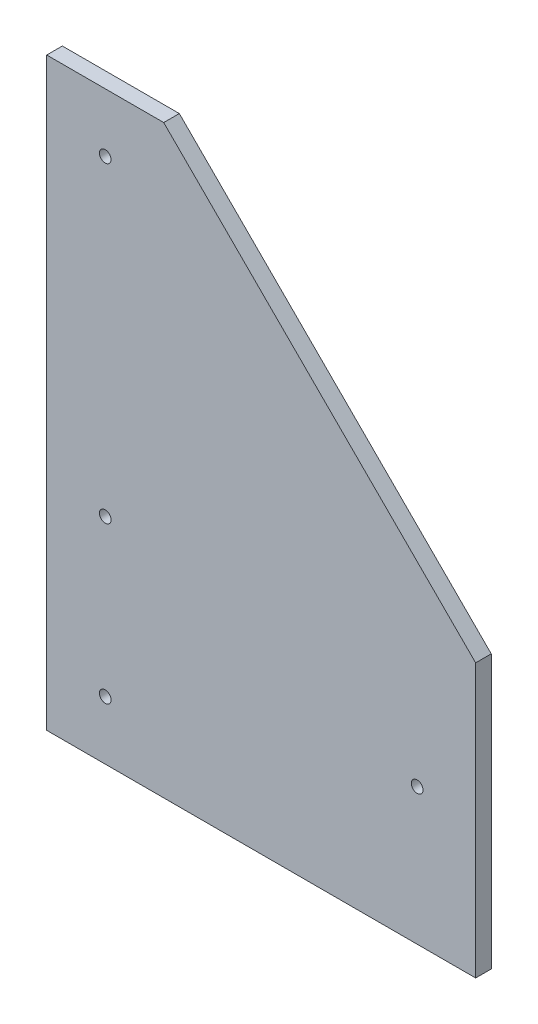
from build123d import *

# Parameters (mm, degrees)
BOSS_EXTRUDE1_DEPTH   = 5.08
F_6_CLEARANCE_HOLE1_D = 3.7973


with BuildPart() as part:
    # Sketch1 → Boss-Extrude1 (new body)
    with BuildSketch(Plane.XY):
        Polygon((0, 0), (139.7, 0), (139.7, 88.9), (38.1, 190.5), (0, 190.5), align=None)
    extrude(amount=BOSS_EXTRUDE1_DEPTH)

    # #6 Clearance Hole1 (through all)
    with Locations(Plane.XY.offset(5.08)):
        with Locations((120.65, 44.45), (19.05, 171.45), (19.05, 19.05), (19.05, 69.85)):
            Hole(F_6_CLEARANCE_HOLE1_D / 2)


solid = part.part
